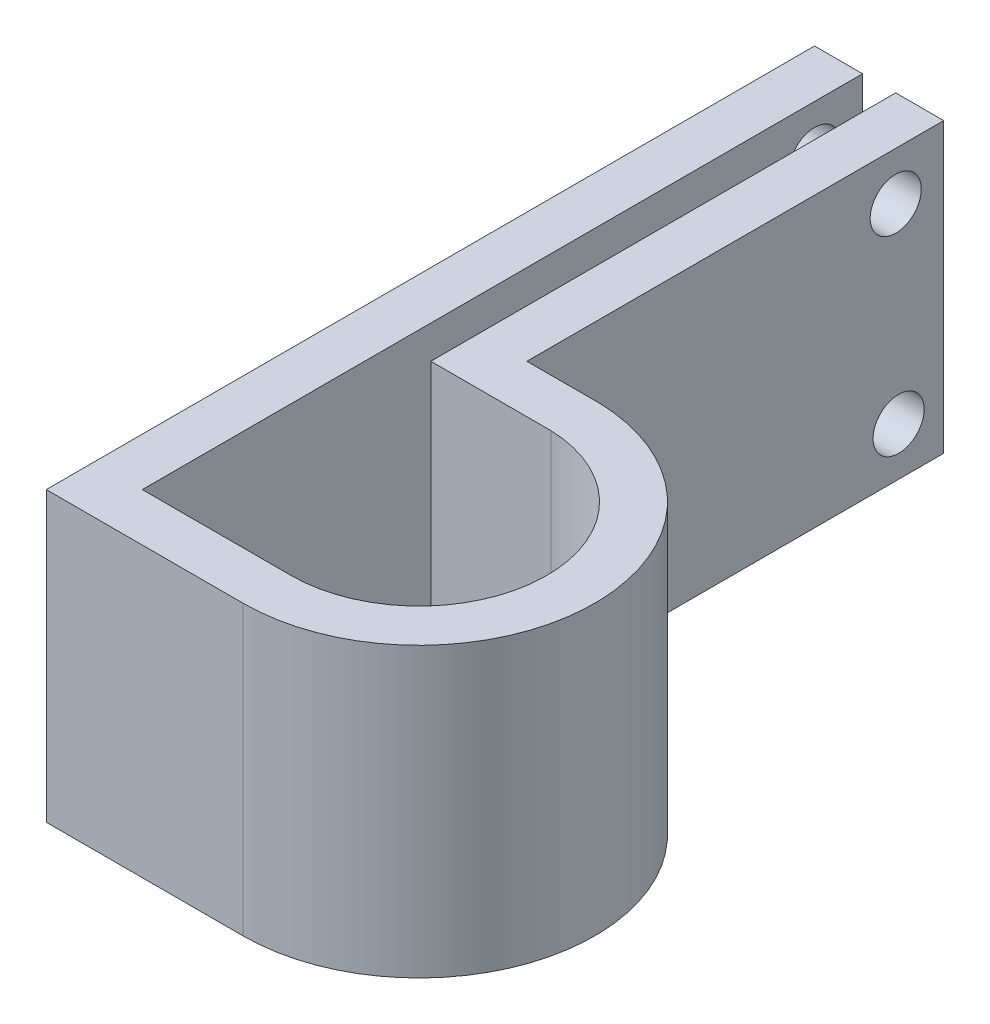
from build123d import *

# Parameters (mm, degrees)
BOSS_EXTRUDE1_DEPTH = 38.1
SKETCH2_R           = 3.3782
CUT_EXTRUDE1_DEPTH  = 18.0815


with BuildPart() as part:
    # Sketch1 → Boss-Extrude1 (new body)
    with BuildSketch(Plane(origin=(0, 0, 0), x_dir=(1, 0, 0), z_dir=(0, 1, 0))):
        with BuildLine():
            Line((-0.008466667, -16.890997878), (-19.693466667, -16.890997878))
            Line((-19.693466667, -16.890997878), (-19.693466667, 78.359002122))
            Line((-19.693466667, 78.359002122), (-26.043466667, 78.359002122))
            Line((-26.043466667, 78.359002122), (-26.043466667, -23.240997878))
            Line((-26.043466667, -23.240997878), (0, -23.240997878))
            ThreePointArc((0, -23.240997878), (23.238651666, -0.33022889), (0.660391106, 23.231613503))
            Line((0.660391106, 23.231613503), (-8.961966667, 23.231613503))
            Line((-8.961966667, 23.231613503), (-8.961966667, 78.359002122))
            Line((-8.961966667, 78.359002122), (-15.311966667, 78.359002122))
            Line((-15.311966667, 78.359002122), (-15.311966667, 16.881613503))
            Line((-15.311966667, 16.881613503), (0.563033333, 16.881613503))
            ThreePointArc((0.563033333, 16.881613503), (16.888582117, -0.285788522), (-0.008466667, -16.890997878))
        make_face()
    extrude(amount=BOSS_EXTRUDE1_DEPTH)

    # Sketch2 → Cut-Extrude1 (cut, through all)
    with BuildSketch(Plane(origin=(-8.961966667, 0, 0), x_dir=(0, 0, -1), z_dir=(1, 0, 0))):
        with Locations((72.009002122, 31.75)):
            Circle(SKETCH2_R)
        with Locations((72.389957145, 6.352856986)):
            Circle(SKETCH2_R)
    extrude(amount=-CUT_EXTRUDE1_DEPTH, mode=Mode.SUBTRACT)


solid = part.part
